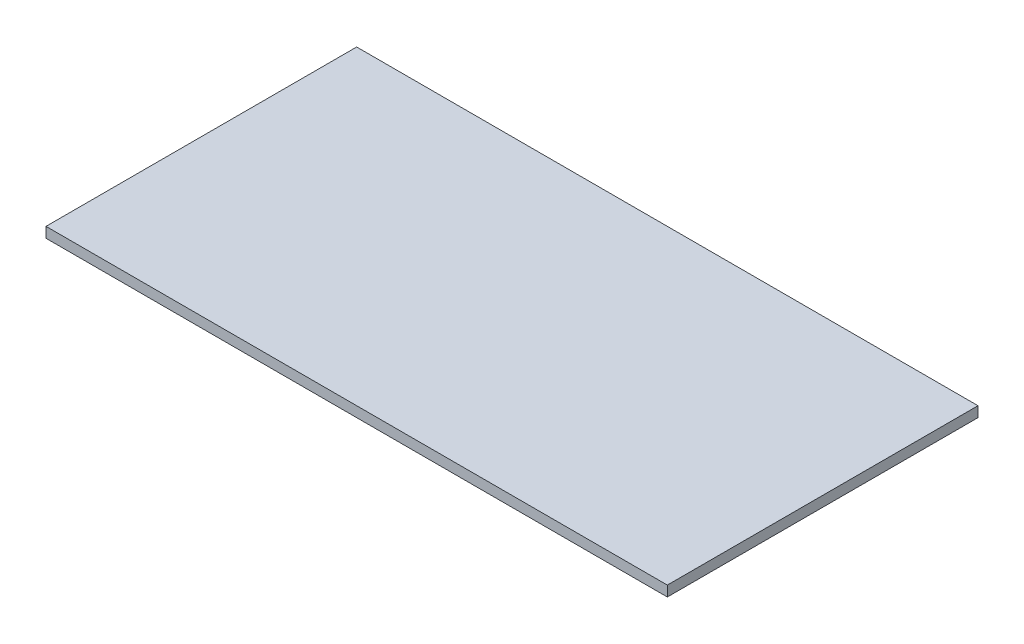
from build123d import *

# Parameters (mm, degrees)
SKETCH1_W           = 600
SKETCH1_H           = 300
BOSS_EXTRUDE1_DEPTH = 10


with BuildPart() as part:
    # Sketch1 → Boss-Extrude1 (new body)
    with BuildSketch(Plane(origin=(0, 0, 0), x_dir=(1, 0, 0), z_dir=(0, 1, 0))):
        Rectangle(SKETCH1_W, SKETCH1_H)
    extrude(amount=BOSS_EXTRUDE1_DEPTH)


solid = part.part
